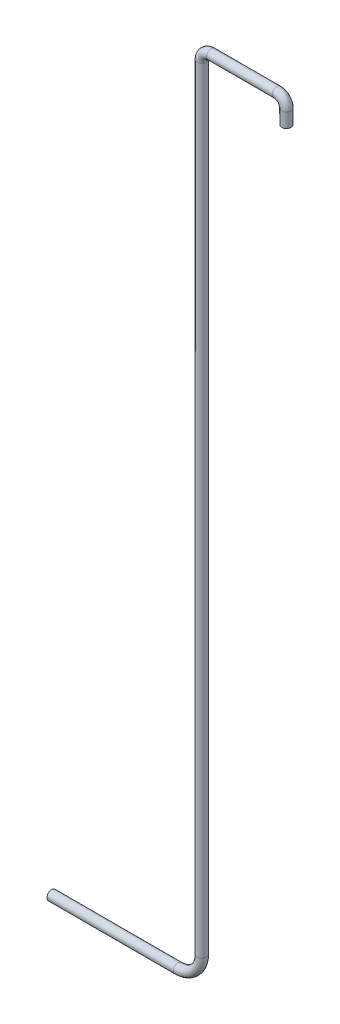
from build123d import *

# Parameters (mm, degrees)
ESQUISSE2_R = 0.1


with BuildPart() as part:
    # Balayage1: sweep along a path in Esquisse1
    with BuildLine(Plane.XY) as balayage1_path:
        Line((0, 0), (0, 0.3))
        ThreePointArc((0, 0.3), (-0.058578644, 0.441421356), (-0.2, 0.5))
        Line((-0.2, 0.5), (-1.584533741, 0.5))
        ThreePointArc((-1.584533741, 0.5), (-1.725955098, 0.441421356), (-1.784533741, 0.3))
        Line((-1.784533741, 0.3), (-1.784533741, -16.05))
        ThreePointArc((-1.784533741, -16.05), (-1.930980351, -16.403553391), (-2.284533741, -16.55))
        Line((-2.284533741, -16.55), (-4.954533741, -16.55))
    # Esquisse2 → Balayage1 (sweep)
    with BuildSketch(Plane(origin=(0, 0, 0), x_dir=(1, 0, 0), z_dir=(0, 1, 0))):
        Circle(ESQUISSE2_R)
    sweep(path=balayage1_path.line)


solid = part.part
